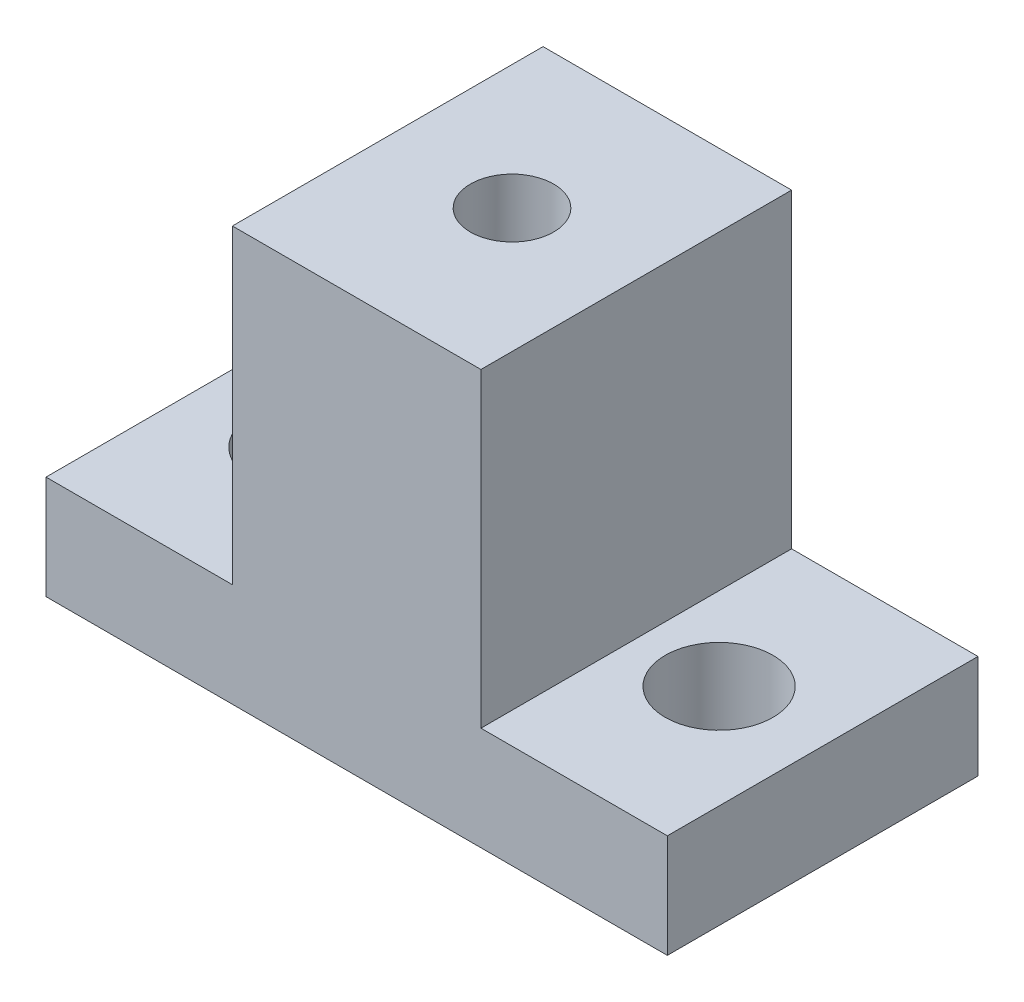
from build123d import *

# Parameters (mm, degrees)
SKETCH1_W               = 38.1
SKETCH1_H               = 19.05
BOSS_EXTRUDE1_DEPTH     = 12.7
SKETCH2_W               = 11.43
SKETCH2_H               = 19.05
CUT_EXTRUDE1_DEPTH      = 20.05
SKETCH3_R               = 3.302
CUT_EXTRUDE2_DEPTH      = 7.35
SKETCH7_R               = 6.35
CUT_EXTRUDE6_DEPTH      = 19.05
F_1_4_20_TAPPED_HOLE2_D = 5.1054


with BuildPart() as part:
    # Sketch1 → Boss-Extrude1 (new body, symmetric)
    with BuildSketch(Plane(origin=(0, 0, 0), x_dir=(1, 0, 0), z_dir=(0, 1, 0))):
        Rectangle(SKETCH1_W, SKETCH1_H)
    extrude(amount=BOSS_EXTRUDE1_DEPTH, both=True)

    # Sketch2 → Cut-Extrude1 (cut, through all)
    with BuildSketch(Plane.XY.offset(9.525)):
        with Locations((-13.335, 3.175)):
            Rectangle(SKETCH2_W, SKETCH2_H)
    cut_extrude1 = extrude(amount=-CUT_EXTRUDE1_DEPTH, mode=Mode.SUBTRACT)

    # Sketch3 → Cut-Extrude2 (cut, through all)
    with BuildSketch(Plane(origin=(0, -6.35, 0), x_dir=(1, 0, 0), z_dir=(0, 1, 0))):
        with Locations((-12.7, 0)):
            Circle(SKETCH3_R)
    cut_extrude2 = extrude(amount=-CUT_EXTRUDE2_DEPTH, mode=Mode.SUBTRACT)

    # Mirror1: Cut-Extrude1, Cut-Extrude2 across plane
    add(cut_extrude1.mirror(Plane(origin=(0, 0, 0), x_dir=(0, 0, 1), z_dir=(1, 0, 0))), mode=Mode.SUBTRACT)
    add(cut_extrude2.mirror(Plane(origin=(0, 0, 0), x_dir=(0, 0, 1), z_dir=(1, 0, 0))), mode=Mode.SUBTRACT)

    # Sketch7 → Cut-Extrude6 (cut)
    with BuildSketch(Plane.XZ.offset(12.7)):
        Circle(SKETCH7_R)
    extrude(amount=-CUT_EXTRUDE6_DEPTH, mode=Mode.SUBTRACT)

    # 1/4-20 Tapped Hole2 (through all)
    with Locations(Plane(origin=(0, 12.7, 0), x_dir=(1, 0, 0), z_dir=(0, 1, 0))):
        with Locations((0, 0)):
            Hole(F_1_4_20_TAPPED_HOLE2_D / 2)


solid = part.part
